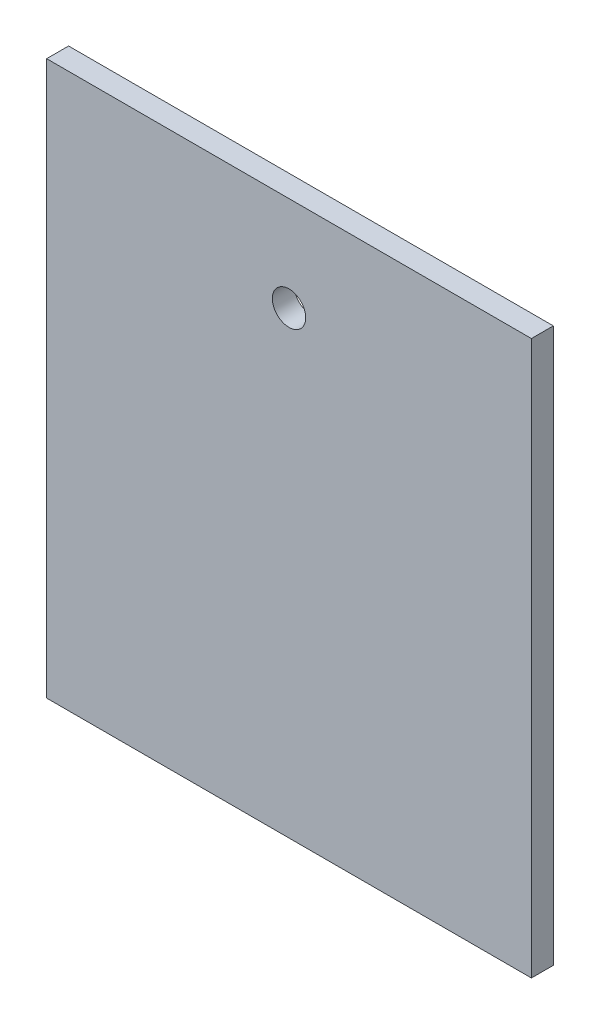
from build123d import *

# Parameters (mm, degrees)
SKETCH1_W           = 70.169166007
SKETCH1_H           = 80.165851149
SKETCH1_R           = 2.415
BOSS_EXTRUDE1_DEPTH = 3.175


with BuildPart() as part:
    # Sketch1 → Boss-Extrude1 (new body)
    with BuildSketch(Plane.XY):
        with Locations((2.051026502, 40.000367746)):
            Rectangle(SKETCH1_W, SKETCH1_H)
        with Locations((2.050209205, 66.35)):
            Circle(SKETCH1_R, mode=Mode.SUBTRACT)
    extrude(amount=BOSS_EXTRUDE1_DEPTH)


solid = part.part
